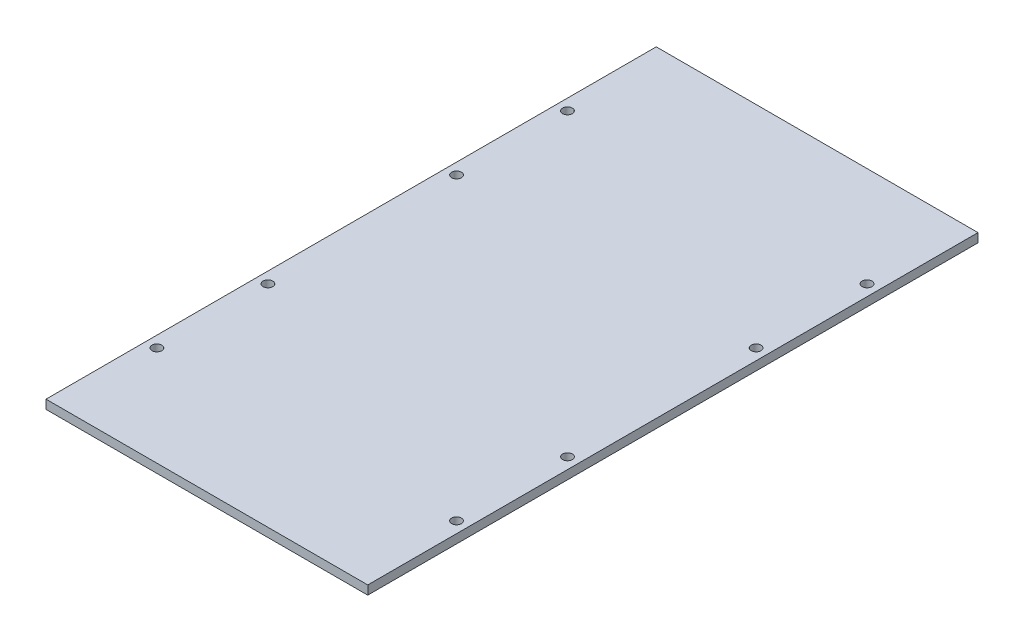
from build123d import *

# Parameters (mm, degrees)
SKETCH2_W           = 145
SKETCH2_H           = 275
BOSS_EXTRUDE1_DEPTH = 4
SKETCH3_R           = 2.2
CUT_EXTRUDE1_DEPTH  = 5


with BuildPart() as part:
    # Sketch2 → Boss-Extrude1 (new body)
    with BuildSketch(Plane(origin=(0, 0, 0), x_dir=(1, 0, 0), z_dir=(0, 1, 0))):
        Rectangle(SKETCH2_W, SKETCH2_H)
    extrude(amount=BOSS_EXTRUDE1_DEPTH)

    # Sketch3 → Cut-Extrude1 (cut, through all)
    with BuildSketch(Plane(origin=(0, 4, 0), x_dir=(1, 0, 0), z_dir=(0, 1, 0))):
        with Locations((-67.5, 92.5)):
            Circle(SKETCH3_R)
        with Locations((-67.5, 42.5)):
            Circle(SKETCH3_R)
        with Locations((-67.5, -42.5)):
            Circle(SKETCH3_R)
        with Locations((-67.5, -92.5)):
            Circle(SKETCH3_R)
        with Locations((67.5, -92.5)):
            Circle(SKETCH3_R)
        with Locations((67.5, -42.5)):
            Circle(SKETCH3_R)
        with Locations((67.5, 42.5)):
            Circle(SKETCH3_R)
        with Locations((67.5, 92.5)):
            Circle(SKETCH3_R)
    extrude(amount=-CUT_EXTRUDE1_DEPTH, mode=Mode.SUBTRACT)


solid = part.part
